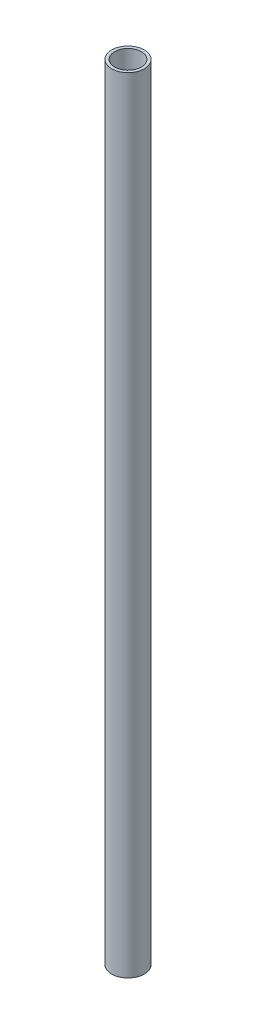
from build123d import *

# Parameters (mm, degrees)
SKETCH1_R           = 12.7
SKETCH1_R_2         = 10.414
BOSS_EXTRUDE1_DEPTH = 609.6


with BuildPart() as part:
    # Sketch1 → Boss-Extrude1 (new body)
    with BuildSketch(Plane(origin=(0, 0, 0), x_dir=(1, 0, 0), z_dir=(0, 1, 0))):
        Circle(SKETCH1_R)
        Circle(SKETCH1_R_2, mode=Mode.SUBTRACT)
    extrude(amount=BOSS_EXTRUDE1_DEPTH)


solid = part.part
